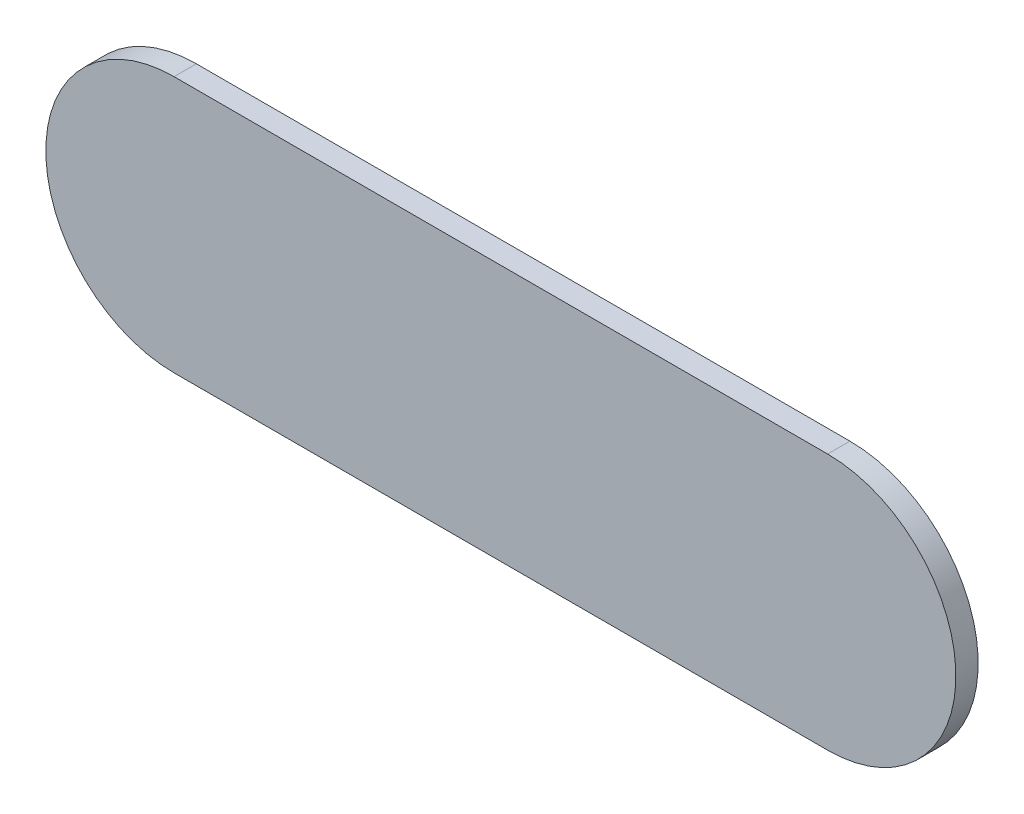
from build123d import *

# Parameters (mm, degrees)
BOSS_EXTRUDE1_DEPTH = 1


with BuildPart() as part:
    # Sketch1 → Boss-Extrude1 (new body)
    with BuildSketch(Plane.XY):
        with BuildLine():
            Line((-14.65, -5.75), (14.65, -5.75))
            ThreePointArc((14.65, -5.75), (20.4, 0), (14.65, 5.75))
            Line((14.65, 5.75), (-14.65, 5.75))
            ThreePointArc((-14.65, 5.75), (-20.4, 0), (-14.65, -5.75))
        make_face()
    extrude(amount=BOSS_EXTRUDE1_DEPTH)


solid = part.part
